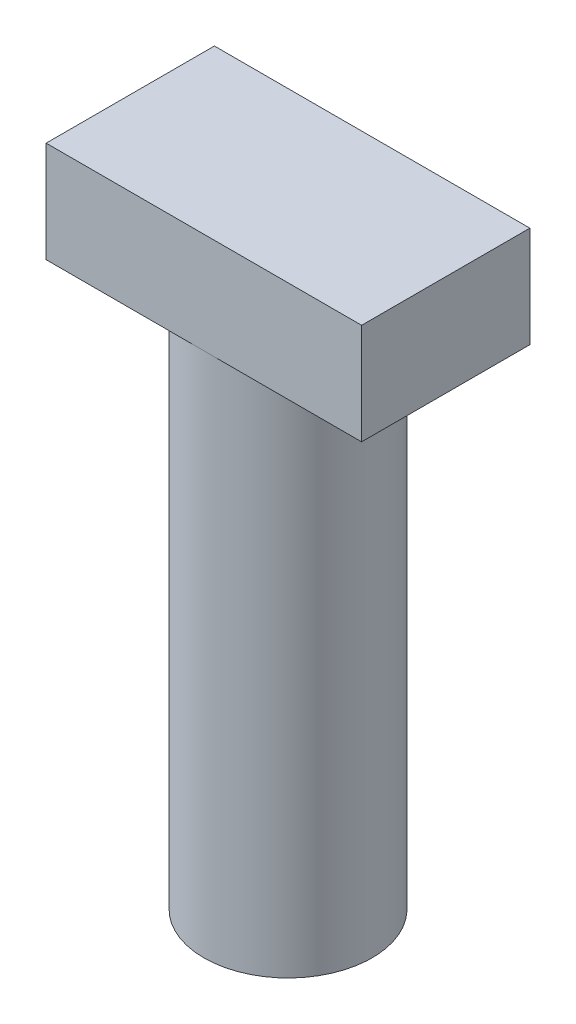
from build123d import *

# Parameters (mm, degrees)
CROQUIS1_R              = 4
SALIENTE_EXTRUIR1_DEPTH = 25
CROQUIS2_W              = 15
CROQUIS2_H              = 8
SALIENTE_EXTRUIR2_DEPTH = 4.8


with BuildPart() as part:
    # Croquis1 → Saliente-Extruir1 (new body)
    with BuildSketch(Plane(origin=(0, 0, 0), x_dir=(1, 0, 0), z_dir=(0, 1, 0))):
        Circle(CROQUIS1_R)
    extrude(amount=SALIENTE_EXTRUIR1_DEPTH)

    # Croquis2 → Saliente-Extruir2 (add)
    with BuildSketch(Plane(origin=(0, 25, 0), x_dir=(1, 0, 0), z_dir=(0, 1, 0))):
        Rectangle(CROQUIS2_W, CROQUIS2_H)
    extrude(amount=SALIENTE_EXTRUIR2_DEPTH)


solid = part.part
